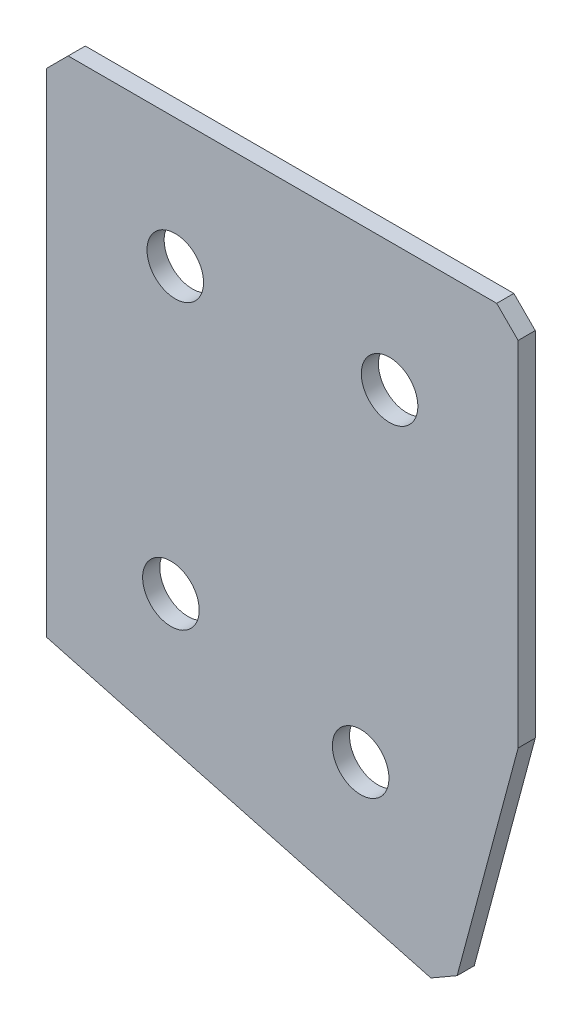
from build123d import *

# Parameters (mm, degrees)
EXTRUDE_1_DEPTH   = 2
HOLE_WIZARD_M61_D = 6.6
CHAMFER_1_SIZE    = 2.5


with BuildPart() as part:
    # Эскиз3 → Бобышка-Вытянуть1 (new body)
    with BuildSketch(Plane(origin=(0, 0, 0), x_dir=(1, 0, 0), z_dir=(0, 0, -1))):
        Polygon((0, 0), (55, 0), (55, 43.678920171), (47.235428647, 72.65669496), (0, 60), align=None)
    extrude(amount=EXTRUDE_1_DEPTH)

    # Отверстие с зазором M61 (through all)
    with Locations(Plane(origin=(0, 0, -2), x_dir=(1, 0, 0), z_dir=(0, 0, -1))):
        with Locations((15, 15), (40, 15), (14.488887394, 48.35314297), (36.628826929, 54.285521889)):
            Hole(HOLE_WIZARD_M61_D / 2)

    # Фаска1
    chamfer_1_edges = [part.edges().sort_by_distance(p)[0] for p in [
        (47.235428647, -72.65669496, -1),
        (55, 0, -1),
        (0, 0, -1),
    ]]
    chamfer(chamfer_1_edges, length=CHAMFER_1_SIZE)


solid = part.part
